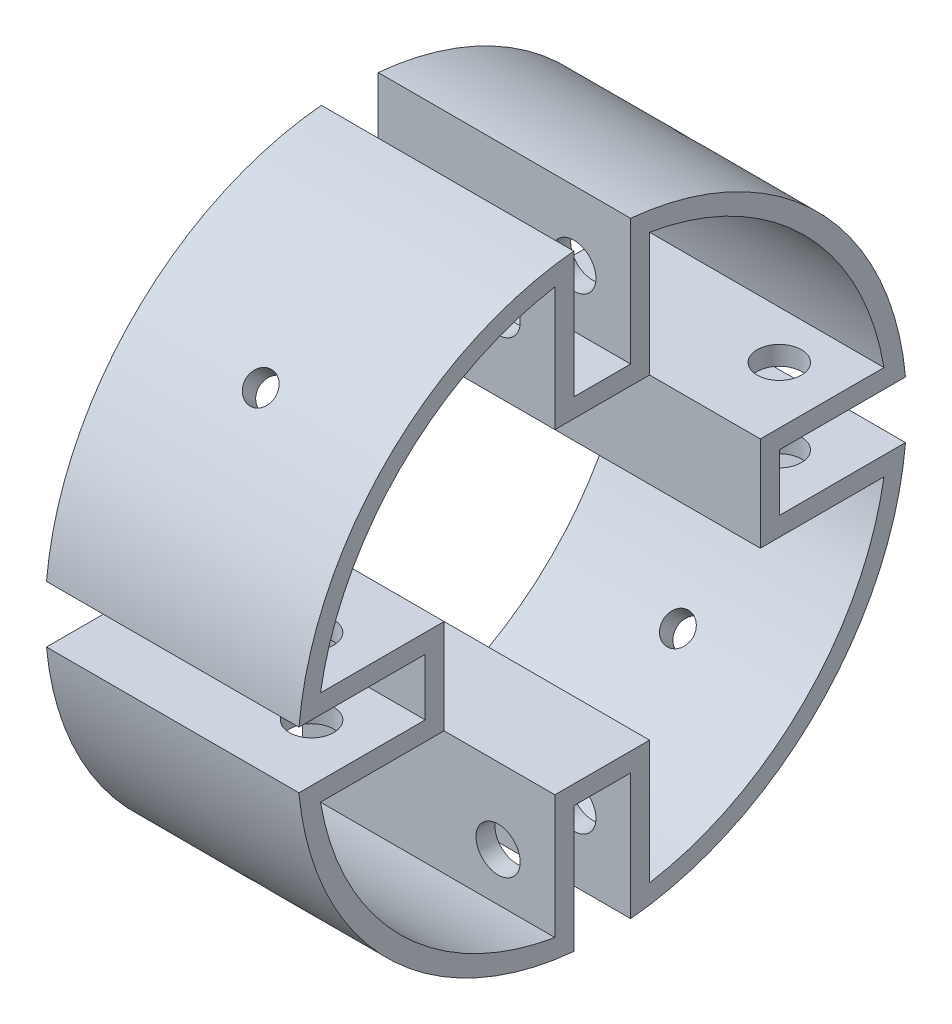
from build123d import *

# Parameters (mm, degrees)
SKETCH4_R               = 48.26
BOSS_EXTRUDE2_DEPTH     = 40
CUT_EXTRUDE1_DEPTH      = 41
CIRPATTERN1_COUNT       = 4
CUT_EXTRUDE2_DEPTH      = 40
CUT_EXTRUDE3_START      = -3
SKETCH7_R               = 3.5
CUT_EXTRUDE3_DEPTH      = 15
CUT_EXTRUDE4_START      = -3
SKETCH8_R               = 3.5
CUT_EXTRUDE4_DEPTH      = 15
CUT_EXTRUDE5_START      = -3.062685
SKETCH11_R              = 2.38125
CUT_EXTRUDE5_DEPTH      = 3.062685
SKETCH13_R              = 2.38125
CUT_EXTRUDE6_DEPTH      = 68.952595383
CUT_EXTRUDE6_DEPTH_BACK = 68.952595383


with BuildPart() as part:
    # Sketch4 → Boss-Extrude2 (new body)
    with BuildSketch(Plane(origin=(0, 0, 0), x_dir=(0, 0, -1), z_dir=(1, 0, 0))):
        Circle(SKETCH4_R)
    extrude(amount=-BOSS_EXTRUDE2_DEPTH)

    # Sketch6 → Cut-Extrude1 (cut, through all)
    with BuildSketch(Plane(origin=(0, 0, 0), x_dir=(0, 0, -1), z_dir=(1, 0, 0))):
        Polygon((-4.5, 277.678371005), (-4.5, 48.049740894), (-4.5, 28.049740894), (4.5, 28.049740894), (4.5, 48.049740894), (4.5, 277.678371005), (4.5, 736.935631227), (-4.5, 736.935631227), align=None)
    cut_extrude1 = extrude(amount=-CUT_EXTRUDE1_DEPTH, mode=Mode.SUBTRACT)

    # CirPattern1: Cut-Extrude1 ×4 about axis
    cirpattern1_axis = Axis((0, 0, 0), (1, 0, 0))
    for i in range(1, CIRPATTERN1_COUNT):
        add(cut_extrude1.rotate(cirpattern1_axis, i * 360 / CIRPATTERN1_COUNT), mode=Mode.SUBTRACT)

    # Sketch9 → Cut-Extrude2 (cut)
    with BuildSketch(Plane(origin=(0, 0, 0), x_dir=(0, 0, -1), z_dir=(1, 0, 0))):
        with BuildLine():
            Line((-25.049740894, -7.5), (-44.634264865, -7.5))
            ThreePointArc((-44.634264865, -7.5), (-32.003652917, -32.003652917), (-7.5, -44.634264865))
            Line((-7.5, -44.634264865), (-7.5, -25.049740894))
            Line((-7.5, -25.049740894), (7.5, -25.049740894))
            Line((7.5, -25.049740894), (7.5, -44.634264865))
            ThreePointArc((7.5, -44.634264865), (32.003652917, -32.003652917), (44.634264865, -7.5))
            Line((44.634264865, -7.5), (25.049740894, -7.5))
            Line((25.049740894, -7.5), (25.049740894, 7.5))
            Line((25.049740894, 7.5), (44.634264865, 7.5))
            ThreePointArc((44.634264865, 7.5), (32.003652917, 32.003652917), (7.5, 44.634264865))
            Line((7.5, 44.634264865), (7.5, 25.049740894))
            Line((7.5, 25.049740894), (-7.5, 25.049740894))
            Line((-7.5, 25.049740894), (-7.5, 44.634264865))
            ThreePointArc((-7.5, 44.634264865), (-32.003652917, 32.003652917), (-44.634264865, 7.5))
            Line((-44.634264865, 7.5), (-25.049740894, 7.5))
            Line((-25.049740894, 7.5), (-25.049740894, -7.5))
        make_face()
    extrude(amount=-CUT_EXTRUDE2_DEPTH, mode=Mode.SUBTRACT)

    # Sketch7 → Cut-Extrude3 (cut)
    with BuildSketch(Plane.XY.offset(-4.5).offset(CUT_EXTRUDE3_START)):
        with Locations((-9, 37.049740894)):
            Circle(SKETCH7_R)
    cut_extrude3 = extrude(amount=CUT_EXTRUDE3_DEPTH, mode=Mode.SUBTRACT)

    # Sketch8 → Cut-Extrude4 (cut)
    with BuildSketch(Plane.XZ.offset(-4.5).offset(CUT_EXTRUDE4_START)):
        with Locations((-9, 37.049740894)):
            Circle(SKETCH8_R)
    cut_extrude4 = extrude(amount=CUT_EXTRUDE4_DEPTH, mode=Mode.SUBTRACT)

    # Mirror1: Cut-Extrude3 across plane
    add(cut_extrude3.mirror(Plane.ZX), mode=Mode.SUBTRACT)

    # Mirror2: Cut-Extrude4 across plane
    add(cut_extrude4.mirror(Plane.XY), mode=Mode.SUBTRACT)

    # Sketch11 → Cut-Extrude5 (cut)
    with BuildSketch(Plane(origin=(0, -34.12497326, 34.12497326), x_dir=(1, 0, 0), z_dir=(0, -0.707106781, 0.707106781)).offset(CUT_EXTRUDE5_START)):
        with Locations((-20, 0)):
            Circle(SKETCH11_R)
    cut_extrude5 = extrude(amount=CUT_EXTRUDE5_DEPTH, mode=Mode.SUBTRACT)

    # Mirror3: Cut-Extrude5 across plane
    add(cut_extrude5.mirror(Plane(origin=(0, 0, 0), x_dir=(0, 0.707106781, 0.707106781), z_dir=(0, 0.707106781, -0.707106781))), mode=Mode.SUBTRACT)

    # Sketch13 → Cut-Extrude6 (cut, two sides)
    with BuildSketch(Plane(origin=(0, 0, 0), x_dir=(1, 0, 0), z_dir=(0, 0.707106781, 0.707106781))) as cut_extrude6_sk:
        with Locations((-20, 0)):
            Circle(SKETCH13_R)
    extrude(amount=CUT_EXTRUDE6_DEPTH, mode=Mode.SUBTRACT)
    extrude(cut_extrude6_sk.sketch, amount=-CUT_EXTRUDE6_DEPTH_BACK, mode=Mode.SUBTRACT)


solid = part.part
